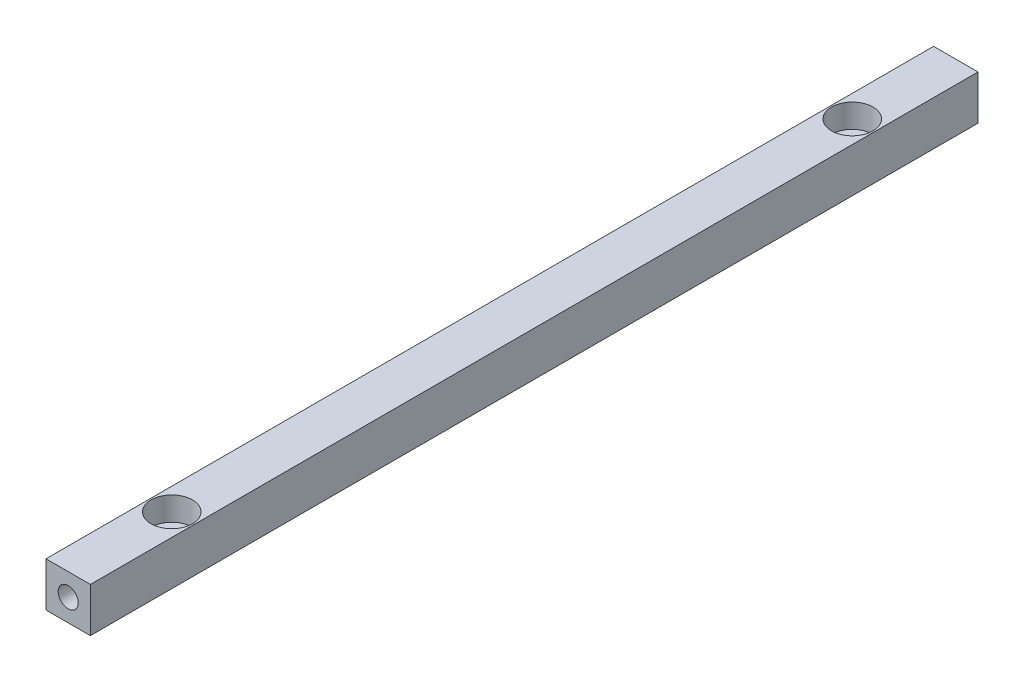
from build123d import *

# Parameters (mm, degrees)
IZIM1_W                     = 15
IZIM1_H                     = 15
Y_KSEKLIK_EKSTR_ZYON1_DEPTH = 150
DELIK1_D                    = 8.5
DELIK1_DEPTH                = 15
DELIK1_CBORE_D              = 14
DELIK1_CBORE_DEPTH          = 8


with BuildPart() as part:
    # Çizim1 → Yükseklik-Ekstrüzyon1 (new body, symmetric)
    with BuildSketch(Plane.XY):
        Rectangle(IZIM1_W, IZIM1_H)
    extrude(amount=Y_KSEKLIK_EKSTR_ZYON1_DEPTH, both=True)

    # Çizim3 → M8 Dişli Delik1 (revolve, cut)
    with BuildSketch(Plane(origin=(0, 0, 150), x_dir=(0, -1, 0), z_dir=(1, 0, 0))):
        Polygon((0, 0), (0, 24.292926105), (3.4, 22.25), (3.4, 0), align=None)
    m8_di_li_delik1 = revolve(axis=Axis((0, 0, 156.35), (0, 0, -1)), mode=Mode.SUBTRACT)

    # Aynalama1: M8 Dişli Delik1 across plane
    add(m8_di_li_delik1.mirror(Plane.XY), mode=Mode.SUBTRACT)

    # Delik1
    with Locations(Plane(origin=(0, 7.5, 0), x_dir=(1, 0, 0), z_dir=(0, 1, 0))):
        with Locations((0, 115)):
            delik1 = CounterBoreHole(DELIK1_D / 2, DELIK1_CBORE_D / 2, DELIK1_CBORE_DEPTH, depth=DELIK1_DEPTH)

    # Aynalama2: Delik1 across plane
    add(delik1.mirror(Plane.XY), mode=Mode.SUBTRACT)


solid = part.part
